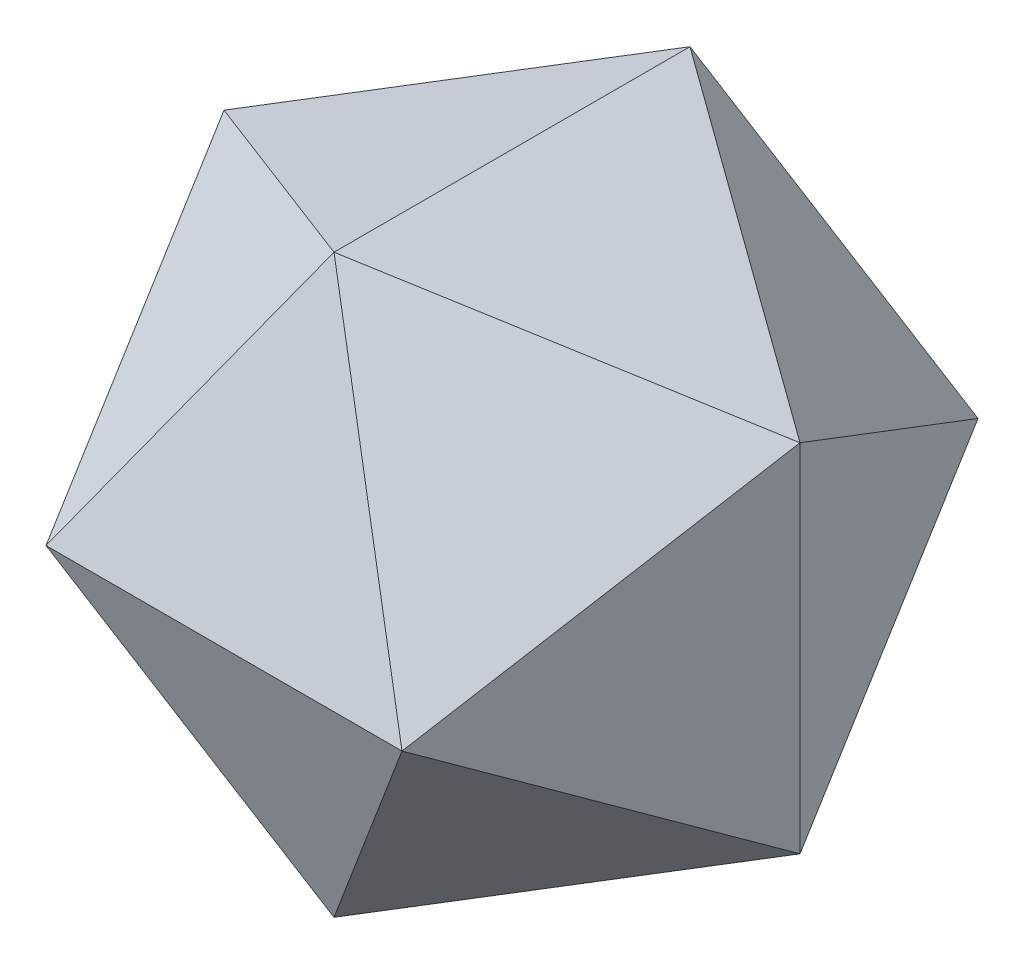
from build123d import *

# Parameters (mm, degrees)
THICKEN2_T2 = 3.81


with BuildPart() as body_1:
    # Sketch25 → Surface-Plane19: a flat surface bounded by the sketch
    with BuildSketch(Plane(origin=(22.166021105, -22.166021105, 22.166021105), x_dir=(0.4082482904638631, -0.40824829046386274, -0.8164965809277263), z_dir=(0.5773502691896261, -0.5773502691896257, 0.5773502691896256)), mode=Mode.PRIVATE) as surface_plane19_2_region:
        Polygon((-23.186921601, 17.960512242), (-3.960799066, -29.060719263), (27.147720667, 11.100207021), align=None)
    surface_plane19_2 = surface_plane19_2_region.sketch.faces()[0]
    # Sketch24 → Surface-Plane18: a flat surface bounded by the sketch
    with BuildSketch(Plane(origin=(-22.166021105, -22.166021105, 22.166021105), x_dir=(-0.4082482904638629, -0.40824829046386274, -0.8164965809277263), z_dir=(0.5773502691896261, 0.5773502691896258, -0.5773502691896255)), mode=Mode.PRIVATE) as surface_plane18_3_region:
        Polygon((-23.186921601, 17.960512242), (-3.960799066, -29.060719263), (27.147720667, 11.100207021), align=None)
    surface_plane18_3 = surface_plane18_3_region.sketch.faces()[0]
    # Sketch26 → Surface-Plane20: a flat surface bounded by the sketch
    with BuildSketch(Plane(origin=(35.865375543, 0, 13.699354438), x_dir=(0.35682208977309, 0, -0.9341723589627158), z_dir=(0.9341723589627158, 0, 0.35682208977309)), mode=Mode.PRIVATE) as surface_plane20_4_region:
        Polygon((-29.329393675, 0), (14.664696837, -25.4), (14.664696837, 25.4), align=None)
    surface_plane20_4 = surface_plane20_4_region.sketch.faces()[0]
    # Sketch23 → Surface-Plane17: a flat surface bounded by the sketch
    with BuildSketch(Plane(origin=(0, -13.699354438, 35.865375543), x_dir=(-1, 0, 0), z_dir=(0, 0.3568220897730898, -0.9341723589627158)), mode=Mode.PRIVATE) as surface_plane17_5_region:
        Polygon((-25.4, 14.664696837), (0, -29.329393675), (25.4, 14.664696837), align=None)
    surface_plane17_5 = surface_plane17_5_region.sketch.faces()[0]
    # Sketch22 → Surface-Plane16: a flat surface bounded by the sketch
    with BuildSketch(Plane(origin=(13.699354438, -35.865375543, 0), x_dir=(0.9341723589627157, 0.35682208977309016, 0), z_dir=(-0.35682208977309016, 0.9341723589627157, 0)), mode=Mode.PRIVATE) as surface_plane16_6_region:
        Polygon((-14.664696837, 25.4), (-14.664696837, -25.4), (29.329393675, 0), align=None)
    surface_plane16_6 = surface_plane16_6_region.sketch.faces()[0]
    # Sketch21 → Surface-Plane15: a flat surface bounded by the sketch
    with BuildSketch(Plane(origin=(-13.699354438, -35.865375543, 0), x_dir=(-0.9341723589627156, 0.3568220897730903, 0), z_dir=(-0.3568220897730903, -0.9341723589627156, 0)), mode=Mode.PRIVATE) as surface_plane15_7_region:
        Polygon((29.329393675, 0), (-14.664696837, 25.4), (-14.664696837, -25.4), align=None)
    surface_plane15_7 = surface_plane15_7_region.sketch.faces()[0]
    # Sketch20 → Surface-Plane14: a flat surface bounded by the sketch
    with BuildSketch(Plane(origin=(-22.166021105, -22.166021105, -22.166021105), x_dir=(-0.8164965809277259, 0.4082482904638632, 0.408248290463863), z_dir=(-0.577350269189626, -0.5773502691896258, -0.5773502691896256)), mode=Mode.PRIVATE) as surface_plane14_8_region:
        Polygon((3.960799066, 29.060719263), (-27.147720667, -11.100207021), (23.186921601, -17.960512242), align=None)
    surface_plane14_8 = surface_plane14_8_region.sketch.faces()[0]
    # Sketch19 → Surface-Plane13: a flat surface bounded by the sketch
    with BuildSketch(Plane(origin=(0, -13.699354438, -35.865375543), x_dir=(-1, 0, 0), z_dir=(0, -0.35682208977309054, -0.9341723589627156)), mode=Mode.PRIVATE) as surface_plane13_9_region:
        Polygon((25.4, 14.664696837), (-25.4, 14.664696837), (0, -29.329393675), align=None)
    surface_plane13_9 = surface_plane13_9_region.sketch.faces()[0]
    # Sketch18 → Surface-Plane12: a flat surface bounded by the sketch
    with BuildSketch(Plane(origin=(22.166021105, -22.166021105, -22.166021105), x_dir=(-0.408248290463863, 0.40824829046386296, -0.8164965809277261), z_dir=(0.5773502691896256, -0.5773502691896261, -0.5773502691896257)), mode=Mode.PRIVATE) as surface_plane12_10_region:
        Polygon((23.186921601, 17.960512242), (3.960799066, -29.060719263), (-27.147720667, 11.100207021), align=None)
    surface_plane12_10 = surface_plane12_10_region.sketch.faces()[0]
    # Sketch17 → Surface-Plane11: a flat surface bounded by the sketch
    with BuildSketch(Plane(origin=(35.865375543, 0, -13.699354438), x_dir=(-0.3568220897730899, 0, -0.9341723589627158), z_dir=(0.9341723589627157, 0, -0.3568220897730898)), mode=Mode.PRIVATE) as surface_plane11_11_region:
        Polygon((29.329393675, 0), (-14.664696837, 25.4), (-14.664696837, -25.4), align=None)
    surface_plane11_11 = surface_plane11_11_region.sketch.faces()[0]
    # Sketch16 → Surface-Plane10: a flat surface bounded by the sketch
    with BuildSketch(Plane(origin=(22.166021105, 22.166021105, -22.166021105), x_dir=(0.40824829046386296, 0.4082482904638628, 0.8164965809277261), z_dir=(-0.5773502691896261, -0.5773502691896257, 0.5773502691896256)), mode=Mode.PRIVATE) as surface_plane10_12_region:
        Polygon((-3.960799066, 29.060719263), (27.147720667, -11.100207021), (-23.186921601, -17.960512242), align=None)
    surface_plane10_12 = surface_plane10_12_region.sketch.faces()[0]
    # Sketch14 → Surface-Plane9: a flat surface bounded by the sketch
    with BuildSketch(Plane(origin=(0, 13.699354438, -35.865375543), x_dir=(1, 0, 0), z_dir=(0, -0.35682208977309054, 0.9341723589627156)), mode=Mode.PRIVATE) as surface_plane9_13_region:
        Polygon((0, 29.329393675), (-25.4, -14.664696837), (25.4, -14.664696837), align=None)
    surface_plane9_13 = surface_plane9_13_region.sketch.faces()[0]
    # Sketch13 → Surface-Plane8: a flat surface bounded by the sketch
    with BuildSketch(Plane(origin=(-35.865375543, 0, -13.699354438), x_dir=(-0.35682208977309016, 0, 0.9341723589627156), z_dir=(-0.9341723589627157, 0, -0.35682208977309016)), mode=Mode.PRIVATE) as surface_plane8_14_region:
        Polygon((14.664696837, -25.4), (-29.329393675, 0), (14.664696837, 25.4), align=None)
    surface_plane8_14 = surface_plane8_14_region.sketch.faces()[0]
    # Sketch12 → Surface-Plane7: a flat surface bounded by the sketch
    with BuildSketch(Plane(origin=(0, 13.699354438, 35.865375543), x_dir=(-1, 0, 0), z_dir=(0, -0.35682208977309043, -0.9341723589627156)), mode=Mode.PRIVATE) as surface_plane7_15_region:
        Polygon((0, 29.329393675), (25.4, -14.664696837), (-25.4, -14.664696837), align=None)
    surface_plane7_15 = surface_plane7_15_region.sketch.faces()[0]
    # Sketch11 → Surface-Plane6: a flat surface bounded by the sketch
    with BuildSketch(Plane(origin=(-35.865375543, 0, 13.699354438), x_dir=(0.3568220897730894, 0, 0.9341723589627159), z_dir=(-0.934172358962716, 0, 0.35682208977308943)), mode=Mode.PRIVATE) as surface_plane6_16_region:
        Polygon((-14.664696837, -25.4), (29.329393675, 0), (-14.664696837, 25.4), align=None)
    surface_plane6_16 = surface_plane6_16_region.sketch.faces()[0]
    # Sketch10 → Surface-Plane5: a flat surface bounded by the sketch
    with BuildSketch(Plane(origin=(-22.166021105, 22.166021105, 22.166021105), x_dir=(-0.8164965809277259, -0.4082482904638633, -0.4082482904638629), z_dir=(0.577350269189626, -0.577350269189626, -0.5773502691896255)), mode=Mode.PRIVATE) as surface_plane5_17_region:
        Polygon((3.960799066, -29.060719263), (23.186921601, 17.960512242), (-27.147720667, 11.100207021), align=None)
    surface_plane5_17 = surface_plane5_17_region.sketch.faces()[0]
    # Sketch9 → Surface-Plane4: a flat surface bounded by the sketch
    with BuildSketch(Plane(origin=(22.166021105, 22.166021105, 22.166021105), x_dir=(0.40824829046386296, 0.4082482904638628, -0.8164965809277261), z_dir=(0.5773502691896261, 0.5773502691896257, 0.5773502691896256)), mode=Mode.PRIVATE) as surface_plane4_18_region:
        Polygon((-3.960799066, 29.060719263), (-23.186921601, -17.960512242), (27.147720667, -11.100207021), align=None)
    surface_plane4_18 = surface_plane4_18_region.sketch.faces()[0]
    # Sketch8 → Surface-Plane3: a flat surface bounded by the sketch
    with BuildSketch(Plane(origin=(13.699354438, 35.865375543, 0), x_dir=(-0.9341723589627156, 0.35682208977309043, 0), z_dir=(-0.35682208977309043, -0.9341723589627156, 0)), mode=Mode.PRIVATE) as surface_plane3_19_region:
        Polygon((-29.329393675, 0), (14.664696837, -25.4), (14.664696837, 25.4), align=None)
    surface_plane3_19 = surface_plane3_19_region.sketch.faces()[0]
    # Sketch7 → Surface-Plane2: a flat surface bounded by the sketch
    with BuildSketch(Plane(origin=(-13.699354438, 35.865375543, 0), x_dir=(0.9341723589627156, 0.3568220897730905, 0), z_dir=(-0.3568220897730905, 0.9341723589627156, 0)), mode=Mode.PRIVATE) as surface_plane2_20_region:
        Polygon((14.664696837, 25.4), (14.664696837, -25.4), (-29.329393675, 0), align=None)
    surface_plane2_20 = surface_plane2_20_region.sketch.faces()[0]
    # Sketch5 → Surface-Plane1: a flat surface bounded by the sketch
    with BuildSketch(Plane(origin=(-22.166021105, 22.166021105, -22.166021105), x_dir=(0.408248290463863, -0.4082482904638628, -0.8164965809277261), z_dir=(0.5773502691896258, -0.5773502691896258, 0.5773502691896256)), mode=Mode.PRIVATE) as surface_plane1_21_region:
        Polygon((3.960799066, 29.060719263), (23.186921601, -17.960512242), (-27.147720667, -11.100207021), align=None)
    surface_plane1_21 = surface_plane1_21_region.sketch.faces()[0]
    # Surface-Knit1: the surfaces knitted into one
    surface_knit1_1 = Shell(Face.sew_faces(surface_plane19_2.faces() + surface_plane18_3.faces() + surface_plane20_4.faces() + surface_plane17_5.faces() + surface_plane16_6.faces() + surface_plane15_7.faces() + surface_plane14_8.faces() + surface_plane13_9.faces() + surface_plane12_10.faces() + surface_plane11_11.faces() + surface_plane10_12.faces() + surface_plane9_13.faces() + surface_plane8_14.faces() + surface_plane7_15.faces() + surface_plane6_16.faces() + surface_plane5_17.faces() + surface_plane4_18.faces() + surface_plane3_19.faces() + surface_plane2_20.faces() + surface_plane1_21.faces())[0])
    add(Solid.thicken(surface_knit1_1, -THICKEN2_T2))


solid = body_1.part
